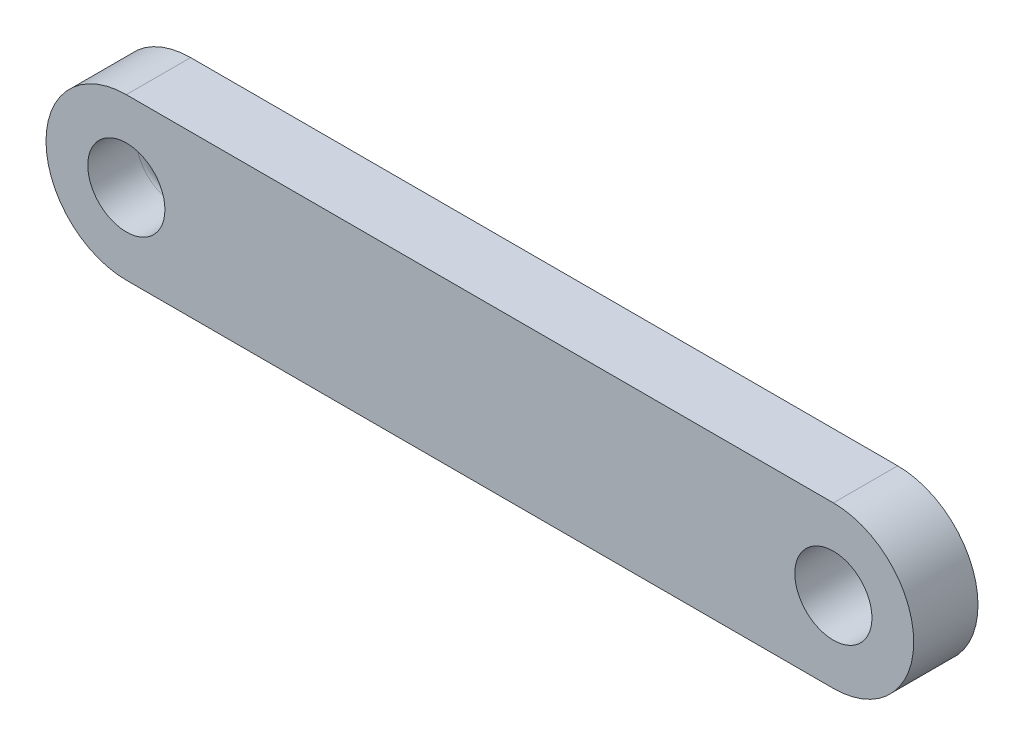
from build123d import *

# Parameters (mm, degrees)
SKETCH1_R           = 12
BOSS_EXTRUDE1_DEPTH = 20
FILLET1_R           = 5


with BuildPart() as part:
    # Sketch1 → Boss-Extrude1 (new body)
    with BuildSketch(Plane.XY):
        with BuildLine():
            Line((0, 25), (220, 25))
            ThreePointArc((220, 25), (245, 0), (220, -25))
            Line((220, -25), (0, -25))
            ThreePointArc((0, -25), (-25, 0), (0, 25))
        make_face()
        with Locations((220, 0)):
            Circle(SKETCH1_R, mode=Mode.SUBTRACT)
        Circle(SKETCH1_R, mode=Mode.SUBTRACT)
    extrude(amount=BOSS_EXTRUDE1_DEPTH)

    # Fillet1
    fillet1_edges = [part.edges().sort_by_distance(p)[0] for p in [
        (-12, 0, 0),
    ]]
    fillet(fillet1_edges, radius=FILLET1_R)


solid = part.part
